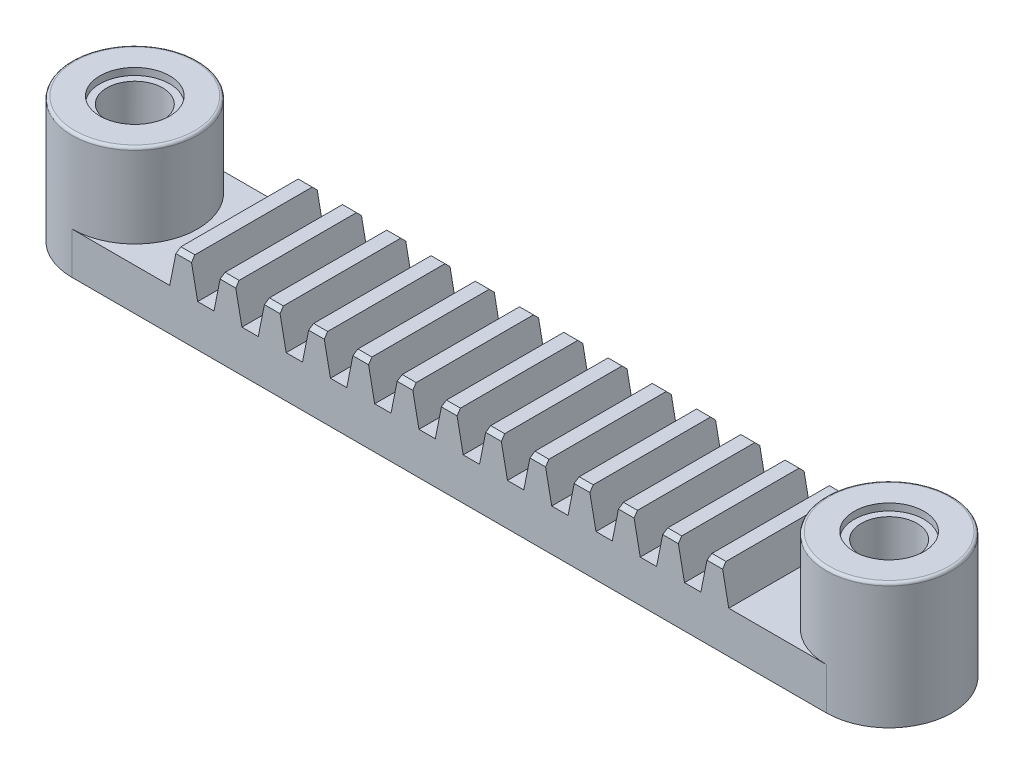
from build123d import *

# Parameters (mm, degrees)
BOSS_EXTRUDE1_DEPTH = 3
SKETCH2_R           = 4.5
BOSS_EXTRUDE2_DEPTH = 6
CUT_EXTRUDE1_REACH  = 35.068
SKETCH3_R           = 2
SKETCH4_R           = 2.5
CUT_EXTRUDE2_DEPTH  = 0.5
BOSS_EXTRUDE4_DEPTH = 9
CHAMFER1_SIZE       = 0.3
FILLET1_R           = 0.2


with BuildPart() as part:
    # Sketch1 → Boss-Extrude1 (new body)
    with BuildSketch(Plane(origin=(0, 0, 0), x_dir=(1, 0, 0), z_dir=(0, 1, 0))):
        with BuildLine():
            Line((-27, 4.5), (27, 4.5))
            ThreePointArc((27, 4.5), (31.5, 0), (27, -4.5))
            Line((27, -4.5), (-27, -4.5))
            ThreePointArc((-27, -4.5), (-31.5, 0), (-27, 4.5))
        make_face()
    extrude(amount=-BOSS_EXTRUDE1_DEPTH)

    # Sketch2 → Boss-Extrude2 (add)
    with BuildSketch(Plane(origin=(0, 0, 0), x_dir=(1, 0, 0), z_dir=(0, 1, 0))):
        with Locations(Location((-27, 0, 0), (0, 0, 270))):
            Circle(SKETCH2_R)
        with Locations(Location((27, 0, 0), (0, 0, 270))):
            Circle(SKETCH2_R)
    extrude(amount=BOSS_EXTRUDE2_DEPTH)

    # Sketch3 → Cut-Extrude1 (cut, up to next)
    with BuildSketch(Plane(origin=(0, 6, 0), x_dir=(1, 0, 0), z_dir=(0, 1, 0)), mode=Mode.PRIVATE) as cut_extrude1_sk1:
        with Locations(Location((-27, 0, 0), (0, 0, 270))):
            Circle(SKETCH3_R)
    cut_extrude1_tool1 = extrude(cut_extrude1_sk1.sketch, amount=-CUT_EXTRUDE1_REACH, mode=Mode.PRIVATE) & part.part
    # Sketch3 → Cut-Extrude1 (cut, up to next)
    with BuildSketch(Plane(origin=(0, 6, 0), x_dir=(1, 0, 0), z_dir=(0, 1, 0)), mode=Mode.PRIVATE) as cut_extrude1_sk2:
        with Locations(Location((27, 0, 0), (0, 0, 270))):
            Circle(SKETCH3_R)
    cut_extrude1_tool2 = extrude(cut_extrude1_sk2.sketch, amount=-CUT_EXTRUDE1_REACH, mode=Mode.PRIVATE) & part.part
    add(cut_extrude1_tool1.solids().sort_by_distance((-27, 6, 0))[0], mode=Mode.SUBTRACT)
    add(cut_extrude1_tool2.solids().sort_by_distance((27, 6, 0))[0], mode=Mode.SUBTRACT)

    # Sketch4 → Cut-Extrude2 (cut)
    with BuildSketch(Plane(origin=(0, 6, 0), x_dir=(1, 0, 0), z_dir=(0, 1, 0))):
        with Locations(Location((-27, 0, 0), (0, 0, 270))):
            Circle(SKETCH4_R)
        with Locations(Location((27, 0, 0), (0, 0, 90))):
            Circle(SKETCH4_R)
    cut_extrude2 = extrude(amount=-CUT_EXTRUDE2_DEPTH, mode=Mode.SUBTRACT)

    # Mirror1: Cut-Extrude2 across plane
    add(cut_extrude2.mirror(Plane(origin=(0, 1.5, 0), x_dir=(0, 0, 1), z_dir=(0, -1, 0))), mode=Mode.SUBTRACT)

    # Sketch21 → Boss-Extrude4 (add)
    with BuildSketch(Plane.XY.offset(4.5)):
        Polygon((-20, 0), (-18, 0), (-18.5, 2.5), (-19.5, 2.5), align=None)
        Polygon((-16.831620529, 0), (-16.331620529, 2.5), (-15.331620529, 2.5), (-14.831620529, 0), align=None)
        Polygon((-13.663241058, 0), (-13.163241058, 2.5), (-12.163241058, 2.5), (-11.663241058, 0), align=None)
        Polygon((-10.494861587, 0), (-9.994861587, 2.5), (-8.994861587, 2.5), (-8.494861587, 0), align=None)
        Polygon((-7.326482116, 0), (-6.826482116, 2.5), (-5.826482116, 2.5), (-5.326482116, 0), align=None)
        Polygon((-4.158102645, 0), (-3.658102645, 2.5), (-2.658102645, 2.5), (-2.158102645, 0), align=None)
        Polygon((-0.989723174, 0), (-0.489723174, 2.5), (0.510276826, 2.5), (1.010276826, 0), align=None)
        Polygon((2.178656297, 0), (2.678656297, 2.5), (3.678656297, 2.5), (4.178656297, 0), align=None)
        Polygon((5.347035768, 0), (5.847035768, 2.5), (6.847035768, 2.5), (7.347035768, 0), align=None)
        Polygon((8.515415239, 0), (9.015415239, 2.5), (10.015415239, 2.5), (10.515415239, 0), align=None)
        Polygon((11.68379471, 0), (12.18379471, 2.5), (13.18379471, 2.5), (13.68379471, 0), align=None)
        Polygon((14.852174181, 0), (15.352174181, 2.5), (16.352174181, 2.5), (16.852174181, 0), align=None)
        Polygon((18.020553652, 0), (18.520553652, 2.5), (19.520553652, 2.5), (20.020553652, 0), align=None)
    extrude(amount=-BOSS_EXTRUDE4_DEPTH)

    # Chamfer1
    chamfer1_edges = [part.edges().sort_by_distance(p)[0] for p in [
        (-6.326482116, 2.5, 4.5),
        (-6.326482116, 2.5, -4.5),
        (-3.158102645, 2.5, 4.5),
        (-3.158102645, 2.5, -4.5),
        (0.010276826, 2.5, 4.5),
        (0.010276826, 2.5, -4.5),
        (3.178656297, 2.5, 4.5),
        (3.178656297, 2.5, -4.5),
        (6.347035768, 2.5, 4.5),
        (6.347035768, 2.5, -4.5),
        (9.515415239, 2.5, 4.5),
        (9.515415239, 2.5, -4.5),
        (12.68379471, 2.5, 4.5),
        (12.68379471, 2.5, -4.5),
        (15.852174181, 2.5, 4.5),
        (15.852174181, 2.5, -4.5),
        (19.020553652, 2.5, 4.5),
        (19.020553652, 2.5, -4.5),
        (-19, 2.5, 4.5),
        (-19, 2.5, -4.5),
        (-15.831620529, 2.5, 4.5),
        (-15.831620529, 2.5, -4.5),
        (-12.663241058, 2.5, 4.5),
        (-12.663241058, 2.5, -4.5),
        (-9.494861587, 2.5, 4.5),
        (-9.494861587, 2.5, -4.5),
    ]]
    chamfer(chamfer1_edges, length=CHAMFER1_SIZE)

    # Fillet1
    fillet1_edges = [part.edges().sort_by_distance(p)[0] for p in [
        (-27, 6, -4.5),
        (27, 6, -4.5),
    ]]
    fillet(fillet1_edges, radius=FILLET1_R)


solid = part.part
